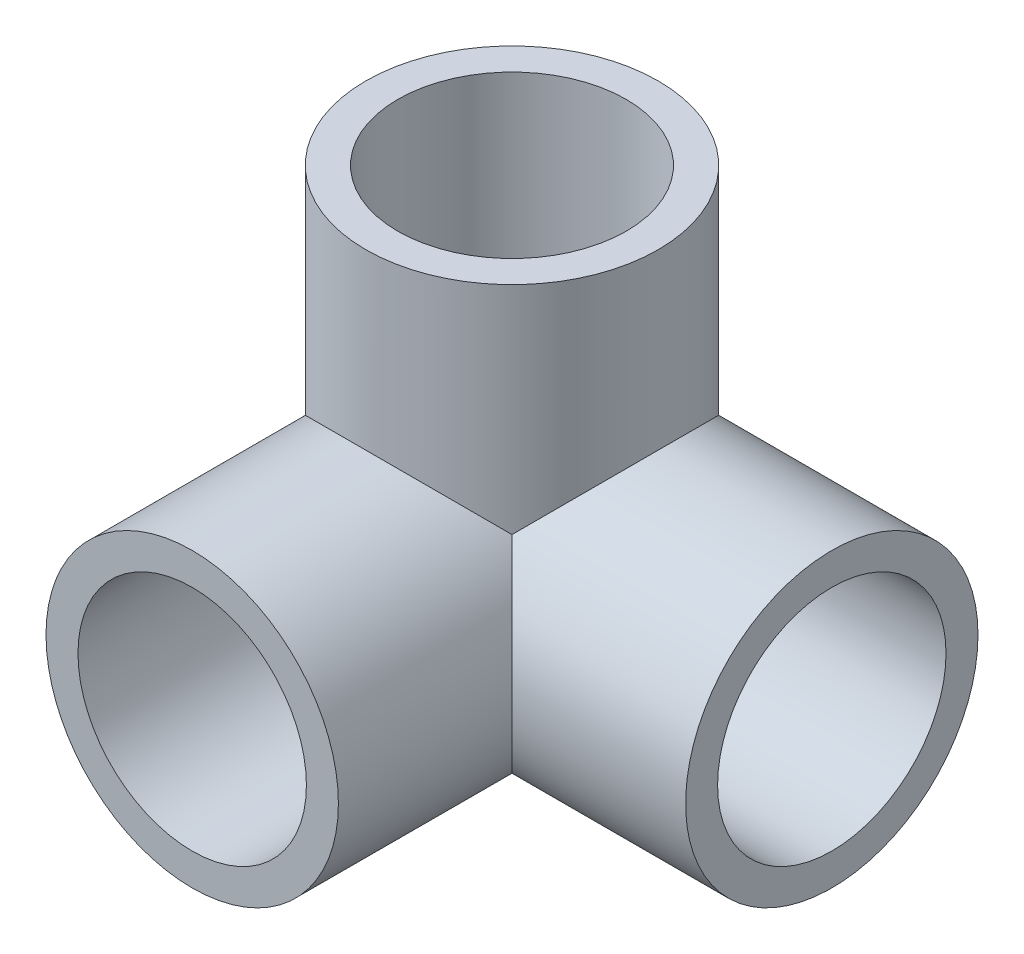
from build123d import *

# Parameters (mm, degrees)
SKETCH_1_R      = 16
SKETCH_1_R_2    = 12.5
EXTRUDE_1_DEPTH = 35
SKETCH_2_R      = 16
SKETCH_2_R_2    = 12.5
EXTRUDE_2_DEPTH = 35
SKETCH_4_R      = 16
SKETCH_4_R_2    = 12.5
EXTRUDE_3_DEPTH = 35
REVOLVE_1_ANGLE = 90


with BuildPart() as part:
    # 草图1 → 凸台-拉伸1 (new body)
    with BuildSketch(Plane.XY):
        Circle(SKETCH_1_R)
        Circle(SKETCH_1_R_2, mode=Mode.SUBTRACT)
    extrude(amount=EXTRUDE_1_DEPTH)

    # 草图2 → 凸台-拉伸2 (add)
    with BuildSketch(Plane(origin=(0, 0, 0), x_dir=(0, 0, -1), z_dir=(1, 0, 0))):
        Circle(SKETCH_2_R)
        Circle(SKETCH_2_R_2, mode=Mode.SUBTRACT)
    extrude(amount=EXTRUDE_2_DEPTH)

    # 草图4 → 凸台-拉伸3 (add)
    with BuildSketch(Plane(origin=(0, 0, 0), x_dir=(1, 0, 0), z_dir=(0, 1, 0))):
        Circle(SKETCH_4_R)
        Circle(SKETCH_4_R_2, mode=Mode.SUBTRACT)
    extrude(amount=EXTRUDE_3_DEPTH)

    # 草图3 → 旋转1 (revolve)
    with BuildSketch(Plane.XY):
        with BuildLine():
            Line((0, 16), (0, -16))
            ThreePointArc((0, -16), (-16, 0), (0, 16))
        make_face()
    revolve(axis=Axis((0, 16, 0), (0, -1, 0)), revolution_arc=REVOLVE_1_ANGLE)


solid = part.part
